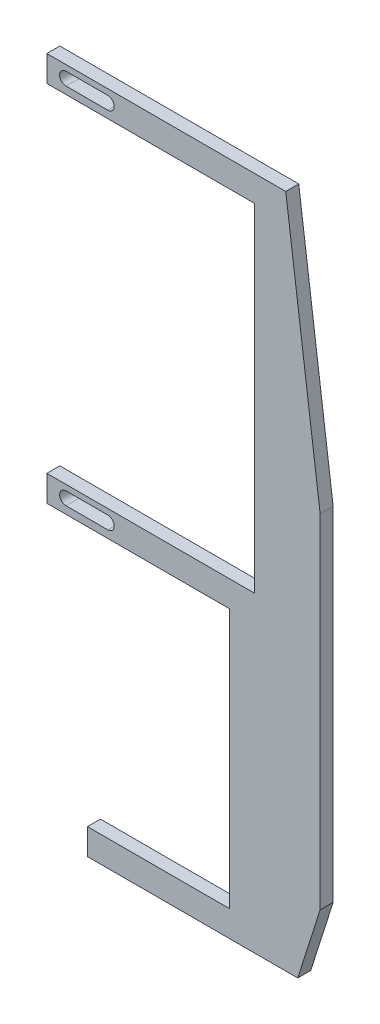
from build123d import *

# Parameters (mm, degrees)
BOSS_EXTRUDE1_DEPTH = 3.175
CUT_EXTRUDE1_DEPTH  = 4.175


with BuildPart() as part:
    # Sketch1 → Boss-Extrude1 (new body)
    with BuildSketch(Plane.XY):
        Polygon((0, 0), (50.8, 0), (50.8, -82.55), (0, -82.55), (0, -88.9), (44.721203233, -88.9), (44.721203233, -152.4), (9.928151849, -152.4), (9.928151849, -158.75), (61.345154174, -158.75), (66.833453826, -141.575386567), (66.833453826, -57.719185396), (58.42, 6.35), (0, 6.35), align=None)
    extrude(amount=BOSS_EXTRUDE1_DEPTH)

    # Sketch2 → Cut-Extrude1 (cut, through all)
    with BuildSketch(Plane.XY.offset(3.175)):
        with BuildLine():
            Line((4.696138357, 4.936538246), (14.893802938, 4.936538246))
            ThreePointArc((14.893802938, 4.936538246), (16.462065142, 3.368276042), (14.893802938, 1.800013839))
            Line((14.893802938, 1.800013839), (4.696138357, 1.800013839))
            ThreePointArc((4.696138357, 1.800013839), (3.127876153, 3.368276042), (4.696138357, 4.936538246))
        make_face()
        with BuildLine():
            Line((4.696138357, -83.929673164), (14.893802938, -83.929673164))
            ThreePointArc((14.893802938, -83.929673164), (16.462065142, -85.497935368), (14.893802938, -87.066197572))
            Line((14.893802938, -87.066197572), (4.696138357, -87.066197572))
            ThreePointArc((4.696138357, -87.066197572), (3.127876153, -85.497935368), (4.696138357, -83.929673164))
        make_face()
    extrude(amount=-CUT_EXTRUDE1_DEPTH, mode=Mode.SUBTRACT)


solid = part.part
